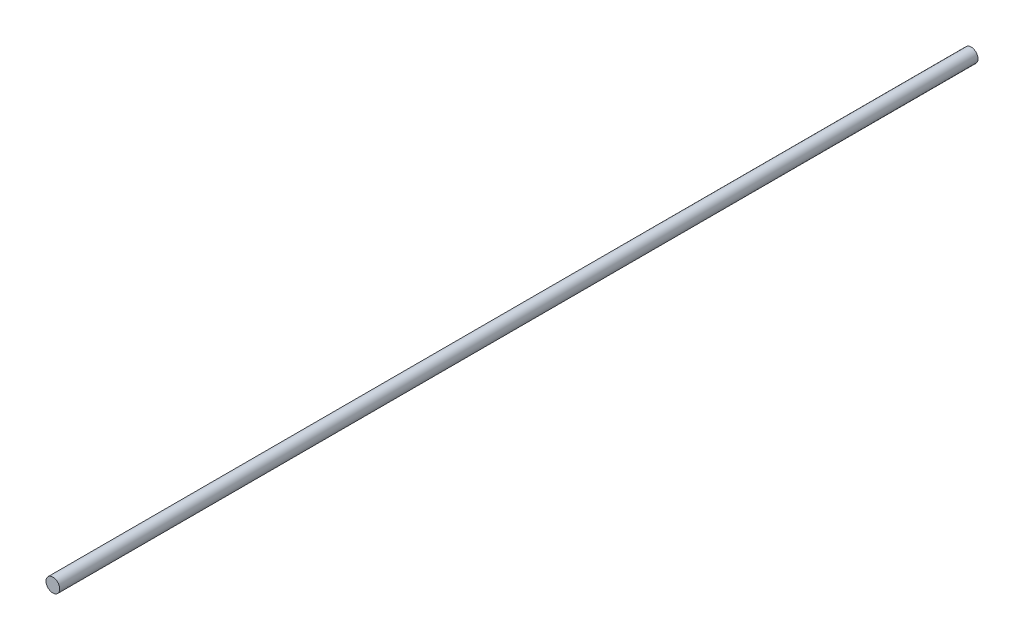
from build123d import *

# Parameters (mm, degrees)
SKETCH1_R           = 0.75
BOSS_EXTRUDE1_DEPTH = 100


with BuildPart() as part:
    # Sketch1 → Boss-Extrude1 (new body)
    with BuildSketch(Plane.XY):
        Circle(SKETCH1_R)
    extrude(amount=BOSS_EXTRUDE1_DEPTH)


solid = part.part
